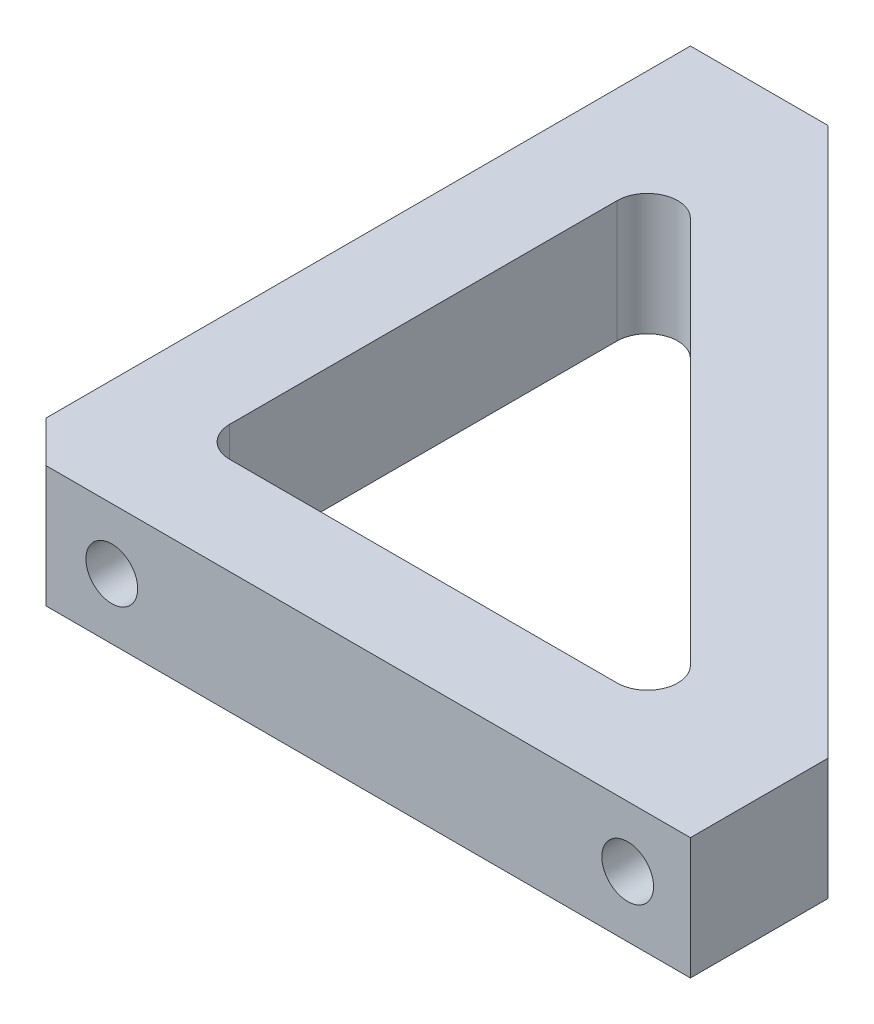
from build123d import *

# Parameters (mm, degrees)
BOSS_EXTRUDE1_DEPTH           = 6.35
FILLET1_R                     = 1.588
TAP_DRILL_FOR_6_32_TAP2_D     = 2.7051
TAP_DRILL_FOR_6_32_TAP2_DEPTH = 6.35
TAP_DRILL_FOR_6_32_TAP2_TIP   = 0.81269403
TAP_DRILL_FOR_6_32_TAP1_D     = 2.7051
TAP_DRILL_FOR_6_32_TAP1_DEPTH = 6.35
TAP_DRILL_FOR_6_32_TAP1_TIP   = 0.81269403
CHAMFER1_SIZE                 = 2.155


with BuildPart() as part:
    # Sketch1 → Boss-Extrude1 (new body)
    with BuildSketch(Plane(origin=(0, 0, 0), x_dir=(1, 0, 0), z_dir=(0, 1, 0))):
        Polygon((0, 0), (0, 35.814), (7.183953537, 35.814), (35.814, 7.183953537), (35.814, 0), align=None)
        Polygon((5.08, 30.73374864), (5.08, 5.08), (30.73374864, 5.08), align=None, mode=Mode.SUBTRACT)
    extrude(amount=BOSS_EXTRUDE1_DEPTH)

    # Fillet1
    fillet1_edges = [part.edges().sort_by_distance(p)[0] for p in [
        (30.73374864, 3.175, -5.08),
        (5.08, 3.175, -30.73374864),
        (5.08, 3.175, -5.08),
    ]]
    fillet(fillet1_edges, radius=FILLET1_R)

    # Tap Drill for #6-32 Tap2
    with Locations(Plane.ZY):
        with Locations((-5.588, 3.175), (-32.5374, 3.175)):
            Hole(TAP_DRILL_FOR_6_32_TAP2_D / 2, depth=TAP_DRILL_FOR_6_32_TAP2_DEPTH)
            with Locations((0, 0, -(TAP_DRILL_FOR_6_32_TAP2_DEPTH + TAP_DRILL_FOR_6_32_TAP2_TIP / 2))):  # 118° drill point
                Cone(0, TAP_DRILL_FOR_6_32_TAP2_D / 2, TAP_DRILL_FOR_6_32_TAP2_TIP, mode=Mode.SUBTRACT)

    # Tap Drill for #6-32 Tap1
    with Locations(Plane.XY):
        with Locations((32.5374, 3.175), (5.588, 3.175)):
            Hole(TAP_DRILL_FOR_6_32_TAP1_D / 2, depth=TAP_DRILL_FOR_6_32_TAP1_DEPTH)
            with Locations((0, 0, -(TAP_DRILL_FOR_6_32_TAP1_DEPTH + TAP_DRILL_FOR_6_32_TAP1_TIP / 2))):  # 118° drill point
                Cone(0, TAP_DRILL_FOR_6_32_TAP1_D / 2, TAP_DRILL_FOR_6_32_TAP1_TIP, mode=Mode.SUBTRACT)

    # Chamfer1
    chamfer1_edges = [part.edges().sort_by_distance(p)[0] for p in [
        (0, 3.175, 0),
    ]]
    chamfer(chamfer1_edges, length=CHAMFER1_SIZE)


solid = part.part
